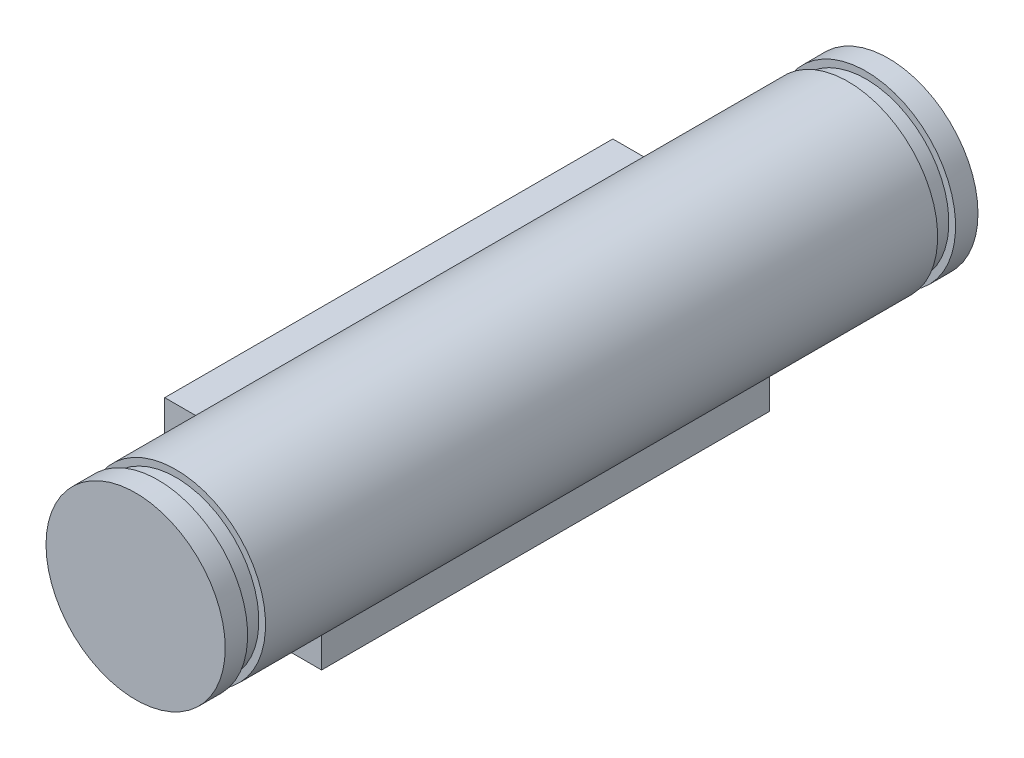
from build123d import *

# Parameters (mm, degrees)
SKETCH_1_R      = 4
EXTRUDE_1_DEPTH = 16.8
SKETCH_2_W      = 0.8
SKETCH_2_H      = 0.3
EXTRUDE_2_DEPTH = 10


with BuildPart() as part:
    # 草图1 → 凸台-拉伸1 (new body, symmetric)
    with BuildSketch(Plane.XY):
        Circle(SKETCH_1_R)
    extrude(amount=EXTRUDE_1_DEPTH, both=True)

    # 草图2 → 切除-旋转1 (revolve, cut)
    with BuildSketch(Plane(origin=(0, 0, 0), x_dir=(0, 0, -1), z_dir=(1, 0, 0))):
        with Locations((-15.4, 3.85)):
            Rectangle(SKETCH_2_W, SKETCH_2_H)
        with Locations((15.4, 3.85)):
            Rectangle(SKETCH_2_W, SKETCH_2_H)
    revolve(axis=Axis((0, 0, -18.8), (0, 0, 1)), mode=Mode.SUBTRACT)

    # 草图3 → 凸台-拉伸2 (add, symmetric)
    with BuildSketch(Plane(origin=(0, 0, 0), x_dir=(-1, 0, 0), z_dir=(0, 0, 1))):
        with BuildLine():
            Line((5.5, 1.5), (3.708099, 1.5))
            ThreePointArc((3.708099, 1.5), (2.839864, 2.816943), (1.53, 3.695822))
            Line((1.53, 3.695822), (1.53, 5.5))
            Line((1.53, 5.5), (-1.5, 5.5))
            Line((-1.5, 5.5), (-1.5, 3.708099))
            ThreePointArc((-1.5, 3.708099), (-2.839864, -2.816943), (3.695822, -1.53))
            Line((3.695822, -1.53), (5.5, -1.53))
            Line((5.5, -1.53), (5.5, 1.5))
        make_face()
    extrude(amount=EXTRUDE_2_DEPTH, both=True)


solid = part.part
